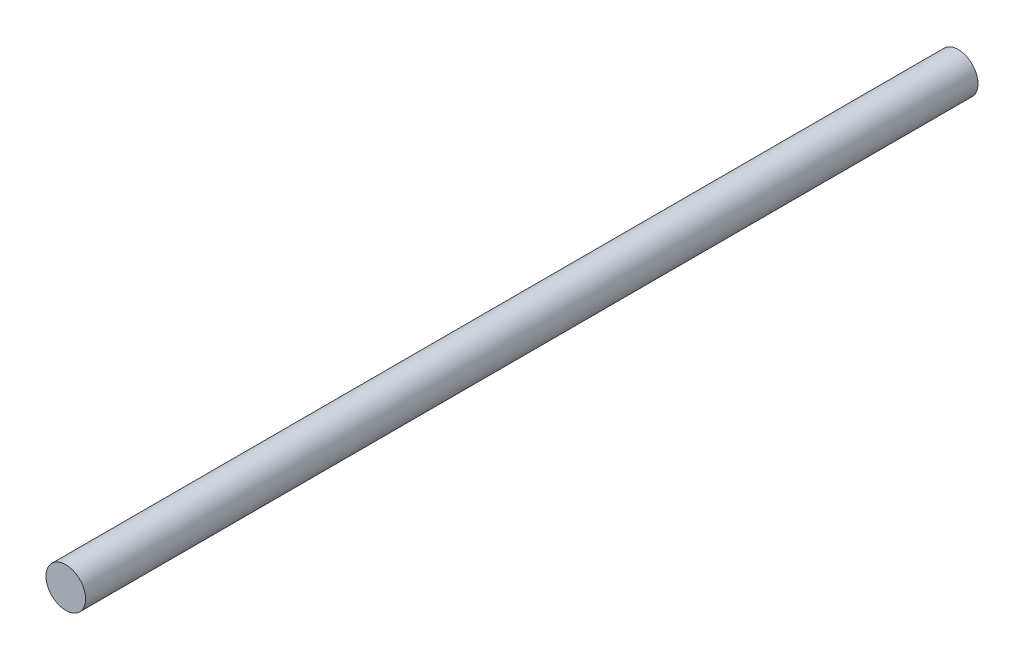
from build123d import *

# Parameters (mm, degrees)
CROQUIS1_R              = 10
SALIENTE_EXTRUIR1_DEPTH = 450


with BuildPart() as part:
    # Croquis1 → Saliente-Extruir1 (new body)
    with BuildSketch(Plane.XY):
        Circle(CROQUIS1_R)
    extrude(amount=SALIENTE_EXTRUIR1_DEPTH)


solid = part.part
